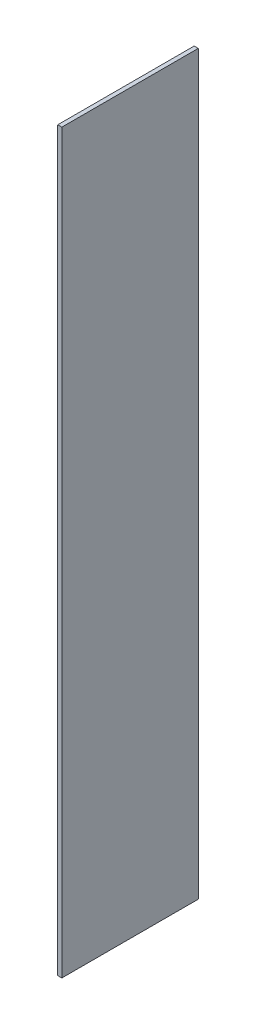
from build123d import *

# Parameters (mm, degrees)
SKETCH1_W           = 1.5
SKETCH1_H           = 50
BOSS_EXTRUDE1_DEPTH = 135


with BuildPart() as part:
    # Sketch1 → Boss-Extrude1 (new body, symmetric)
    with BuildSketch(Plane(origin=(0, 0, 0), x_dir=(1, 0, 0), z_dir=(0, 1, 0))):
        Rectangle(SKETCH1_W, SKETCH1_H)
    extrude(amount=BOSS_EXTRUDE1_DEPTH, both=True)


solid = part.part
